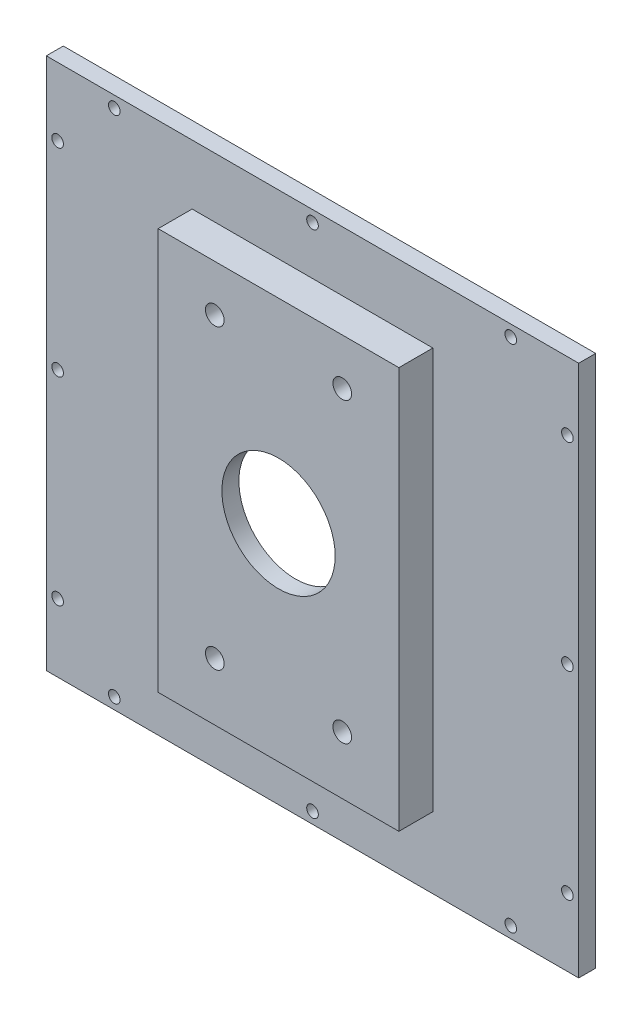
from build123d import *

# Parameters (mm, degrees)
SKETCH_1_W               = 94
SKETCH_1_H               = 94
SKETCH_1_W_2             = 42.5
SKETCH_1_H_2             = 70.9
EXTRUDE_1_DEPTH          = 3
SKETCH_1_5_W             = 42.5
SKETCH_1_5_H             = 70.9
SKETCH_1_5_W_2           = 32.5
SKETCH_1_5_H_2           = 60.9
EXTRUDE_2_DEPTH          = 6
SKETCH_2_W               = 42.5
SKETCH_2_H               = 70.9
SKETCH_2_R               = 10
EXTRUDE_3_DEPTH          = 3
HOLE_WIZARD_M4_1_D       = 3.3
HOLE_WIZARD_M4_1_DEPTH   = 11.5
HOLE_WIZARD_M4_1_TIP     = 0.991420021
HOLE_WIZARD_M2_5_1_D     = 2.05
HOLE_WIZARD_M2_5_1_DEPTH = 7.25
HOLE_WIZARD_M2_5_1_TIP   = 0.615882135
HOLE_WIZARD_M2_5_2_D     = 2.05
HOLE_WIZARD_M2_5_2_DEPTH = 7.25
HOLE_WIZARD_M2_5_2_TIP   = 0.615882135


with BuildPart() as part:
    # 草图1 → 凸台-拉伸1 (new body)
    with BuildSketch(Plane.XY):
        with Locations((0, -2)):
            Rectangle(SKETCH_1_W, SKETCH_1_H)
        with Locations((0, -1)):
            Rectangle(SKETCH_1_W_2, SKETCH_1_H_2, mode=Mode.SUBTRACT)
    extrude(amount=EXTRUDE_1_DEPTH)

    # 草图1<5> → 凸台-拉伸2 (add)
    with BuildSketch(Plane.XY):
        with Locations((0, -1)):
            Rectangle(SKETCH_1_5_W, SKETCH_1_5_H)
        Rectangle(SKETCH_1_5_W_2, SKETCH_1_5_H_2, mode=Mode.SUBTRACT)
    extrude(amount=EXTRUDE_2_DEPTH)

    # 草图2 → 凸台-拉伸3 (add)
    with BuildSketch(Plane.XY.offset(6)):
        with Locations((0, -1)):
            Rectangle(SKETCH_2_W, SKETCH_2_H)
        Circle(SKETCH_2_R, mode=Mode.SUBTRACT)
    extrude(amount=EXTRUDE_3_DEPTH)

    # M4 螺纹孔1
    with Locations(Plane.XY.offset(9)):
        with Locations((11.25, 26.25), (-11.25, 26.25), (-11.25, -26.25), (11.25, -26.25)):
            Hole(HOLE_WIZARD_M4_1_D / 2, depth=HOLE_WIZARD_M4_1_DEPTH)
            with Locations((0, 0, -(HOLE_WIZARD_M4_1_DEPTH + HOLE_WIZARD_M4_1_TIP / 2))):  # 118° drill point
                Cone(0, HOLE_WIZARD_M4_1_D / 2, HOLE_WIZARD_M4_1_TIP, mode=Mode.SUBTRACT)

    # M2.5 螺纹孔1
    with Locations(Plane.XY.offset(3)):
        with Locations((-45, 33), (-45, -2), (-45, -37), (-35, 43), (0, 43), (35, 43), (45, 33)):
            Hole(HOLE_WIZARD_M2_5_1_D / 2, depth=HOLE_WIZARD_M2_5_1_DEPTH)
            with Locations((0, 0, -(HOLE_WIZARD_M2_5_1_DEPTH + HOLE_WIZARD_M2_5_1_TIP / 2))):  # 118° drill point
                Cone(0, HOLE_WIZARD_M2_5_1_D / 2, HOLE_WIZARD_M2_5_1_TIP, mode=Mode.SUBTRACT)

    # M2.5 螺纹孔2
    with Locations(Plane.XY.offset(3)):
        with Locations((45, -2), (45, -37), (35, -47), (0, -47), (-35, -47)):
            Hole(HOLE_WIZARD_M2_5_2_D / 2, depth=HOLE_WIZARD_M2_5_2_DEPTH)
            with Locations((0, 0, -(HOLE_WIZARD_M2_5_2_DEPTH + HOLE_WIZARD_M2_5_2_TIP / 2))):  # 118° drill point
                Cone(0, HOLE_WIZARD_M2_5_2_D / 2, HOLE_WIZARD_M2_5_2_TIP, mode=Mode.SUBTRACT)


solid = part.part
